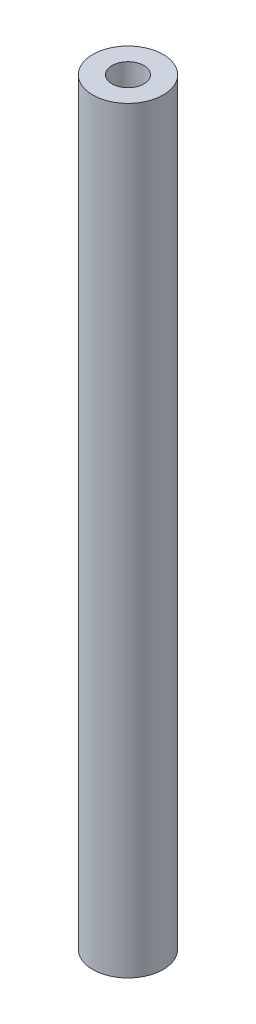
from build123d import *

# Parameters (mm, degrees)
SKETCH1_R           = 4.7625
SKETCH1_R_2         = 2.159
BOSS_EXTRUDE1_DEPTH = 102.616


with BuildPart() as part:
    # Sketch1 → Boss-Extrude1 (new body)
    with BuildSketch(Plane(origin=(0, 0, 0), x_dir=(1, 0, 0), z_dir=(0, 1, 0))):
        Circle(SKETCH1_R)
        Circle(SKETCH1_R_2, mode=Mode.SUBTRACT)
    extrude(amount=BOSS_EXTRUDE1_DEPTH)


solid = part.part
